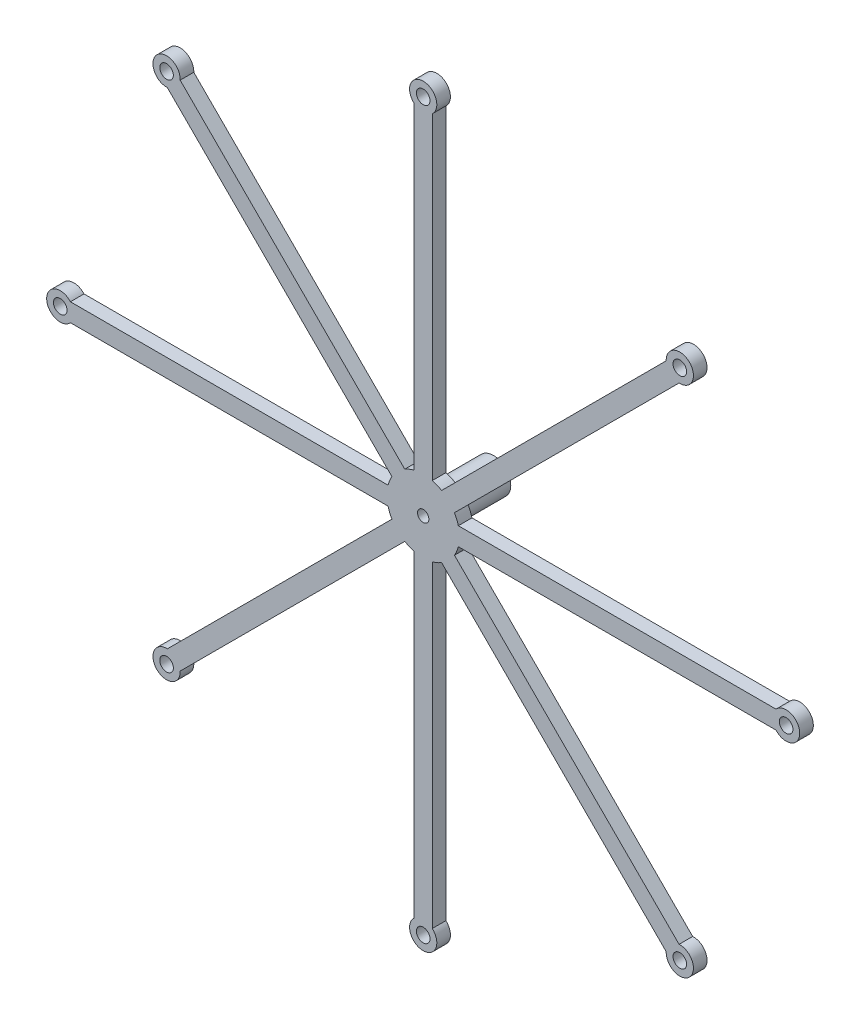
from build123d import *

# Parameters (mm, degrees)
SKETCH_1_R               = 8
EXTRUDE_1_DEPTH          = 3
SKETCH_2_R               = 1.5
EXTRUDE_760_DEPTH        = 3
PATTERN_CIRCULAR_3_COUNT = 8
SKETCH_3_R               = 3.8
EXTRUDE_3_DEPTH          = 12.5
SKETCH_4_R               = 1.25
CUT_EXTRUDE_1_DEPTH      = 119.398690871


with BuildPart() as part:
    # 草图1 → 凸台-拉伸1 (new body)
    with BuildSketch(Plane.XY):
        Circle(SKETCH_1_R)
    extrude(amount=EXTRUDE_1_DEPTH)

    # 草图2 → Extrude 760 (add)
    with BuildSketch(Plane.XY.offset(3)):
        with BuildLine():
            ThreePointArc((7.745966692, 2), (8, 0), (7.745966692, -2))
            Line((7.745966692, -2), (77.763932023, -2))
            ThreePointArc((77.763932023, -2), (83, 0), (77.763932023, 2))
            Line((77.763932023, 2), (7.745966692, 2))
        make_face()
        with Locations((80, 0)):
            Circle(SKETCH_2_R, mode=Mode.SUBTRACT)
    extrude_760 = extrude(amount=-EXTRUDE_760_DEPTH)

    # 阵列(圆周)3: Extrude 760 ×8 about axis
    pattern_circular_3_axis = Axis((0, 0, 0), (0, 0, 1))
    for i in range(1, PATTERN_CIRCULAR_3_COUNT):
        add(extrude_760.rotate(pattern_circular_3_axis, i * 360 / PATTERN_CIRCULAR_3_COUNT))

    # 草图3 → 凸台-拉伸3 (add)
    with BuildSketch(Plane(origin=(0, 0, 0), x_dir=(-1, 0, 0), z_dir=(0, 0, -1))):
        with Locations(Location((0, 0, 0), (0, 0, 180))):
            Circle(SKETCH_3_R)
    extrude(amount=EXTRUDE_3_DEPTH)

    # 草图4 → 切除-拉伸1 (cut, through all)
    with BuildSketch(Plane(origin=(0, 0, -12.5), x_dir=(-1, 0, 0), z_dir=(0, 0, -1))):
        Circle(SKETCH_4_R)
    extrude(amount=-CUT_EXTRUDE_1_DEPTH, mode=Mode.SUBTRACT)


solid = part.part
